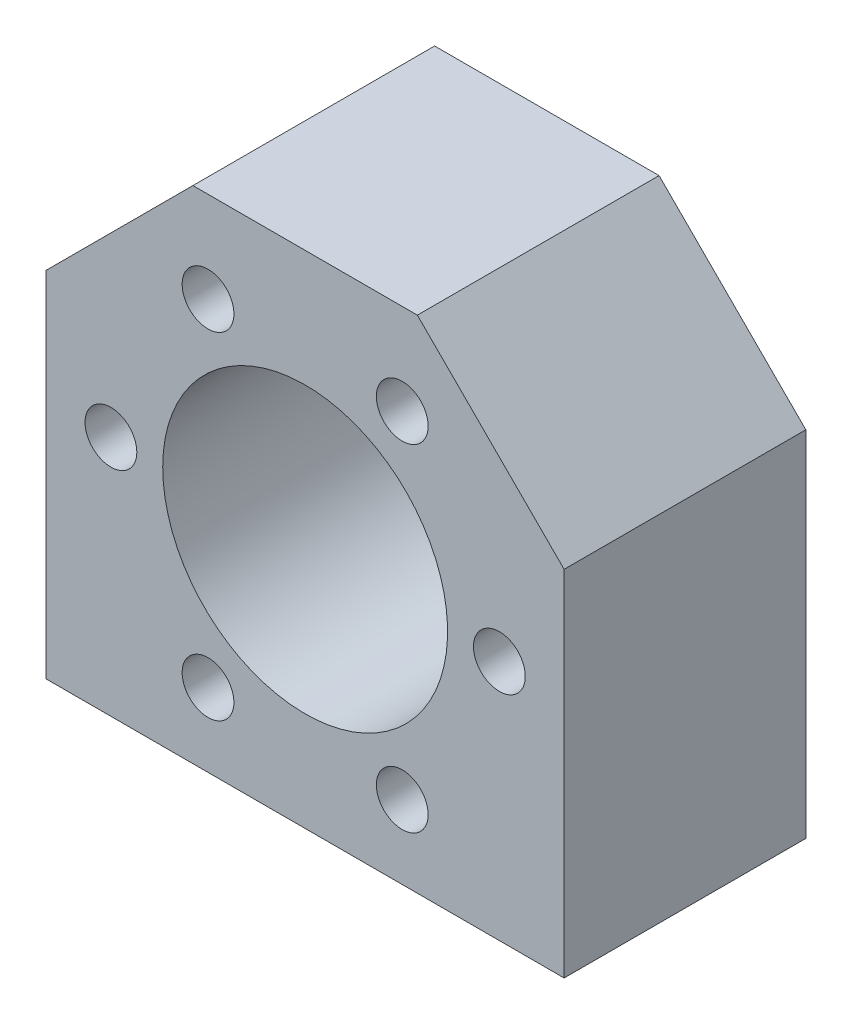
from build123d import *

# Parameters (mm, degrees)
DODANIE_WYCI_GNI_CIE1_DEPTH = 28
SZKIC2_R                    = 16.5
WYTNIJ_WYCI_GNI_CIE1_DEPTH  = 28
SZKIC3_R                    = 3
WYTNIJ_WYCI_GNI_CIE2_DEPTH  = 28
SZYK_KO_OWY1_COUNT          = 6
SZKIC4_R                    = 4
WYTNIJ_WYCI_GNI_CIE3_DEPTH  = 20


with BuildPart() as part:
    # Szkic1 → Dodanie-wyciągnięcie1 (new body)
    with BuildSketch(Plane.XY):
        Polygon((-18.893335163, -36.401668679), (-18.893335163, 4.598331321), (-1.893335163, 21.598331321), (24.106664837, 21.598331321), (41.106664837, 4.598331321), (41.106664837, -36.401668679), align=None)
    extrude(amount=DODANIE_WYCI_GNI_CIE1_DEPTH)

    # Szkic2 → Wytnij-wyciągnięcie1 (cut)
    with BuildSketch(Plane(origin=(0, 0, 0), x_dir=(-1, 0, 0), z_dir=(0, 0, -1))):
        with Locations((-11.106664837, -8.401668679)):
            Circle(SZKIC2_R)
    extrude(amount=-WYTNIJ_WYCI_GNI_CIE1_DEPTH, mode=Mode.SUBTRACT)

    # Szkic3 → Wytnij-wyciągnięcie2 (cut)
    with BuildSketch(Plane(origin=(0, 0, 0), x_dir=(-1, 0, 0), z_dir=(0, 0, -1))):
        with Locations((-33.606664837, -8.401668679)):
            Circle(SZKIC3_R)
    wytnij_wyci_gni_cie2 = extrude(amount=-WYTNIJ_WYCI_GNI_CIE2_DEPTH, mode=Mode.SUBTRACT)

    # Szyk kołowy1: Wytnij-wyciągnięcie2 ×6 about axis
    szyk_ko_owy1_axis = Axis((11.106664837, -8.401668679, 0), (0, 0, 1))
    for i in range(1, SZYK_KO_OWY1_COUNT):
        add(wytnij_wyci_gni_cie2.rotate(szyk_ko_owy1_axis, i * 360 / SZYK_KO_OWY1_COUNT), mode=Mode.SUBTRACT)

    # Szkic4 → Wytnij-wyciągnięcie3 (cut)
    with BuildSketch(Plane.XZ.offset(36.401668679)):
        with Locations((-10.893335163, 14)):
            Circle(SZKIC4_R)
        with Locations((33.106664837, 14)):
            Circle(SZKIC4_R)
    extrude(amount=-WYTNIJ_WYCI_GNI_CIE3_DEPTH, mode=Mode.SUBTRACT)


solid = part.part
